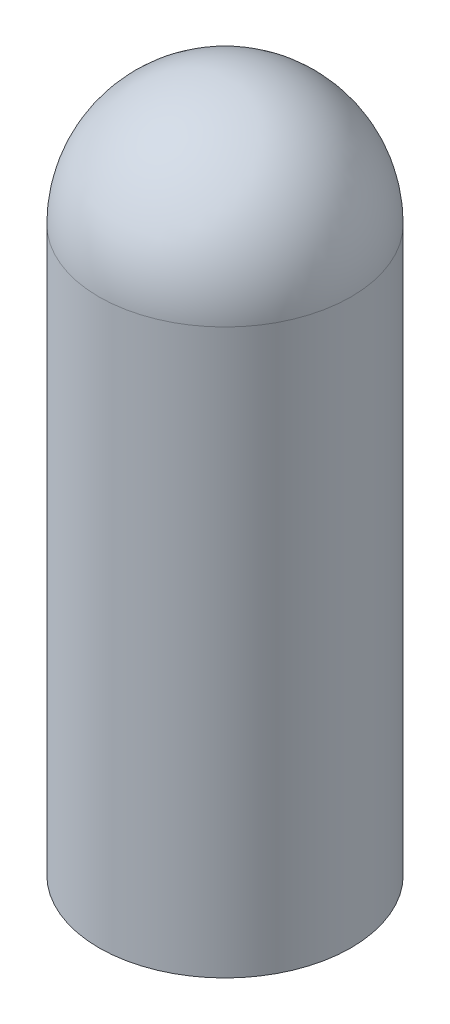
from build123d import *

# Parameters (mm, degrees)
SHELL1_T = 1.5


with BuildPart() as part:
    # Sketch1 → Revolve6 (revolve)
    with BuildSketch(Plane.XY):
        with BuildLine():
            Line((0, 42.5), (0, 52))
            ThreePointArc((0, 52), (-6.717514421, 49.217514421), (-9.5, 42.5))
            Line((-9.5, 42.5), (-9.5, 0))
            Line((-9.5, 0), (0, 0))
            Line((0, 0), (0, 42.5))
        make_face()
    revolve(axis=Axis((0, 42.5, 0), (0, 1, 0)))

    # Shell1 (no face opened: a closed hollow body)
    add(offset(amount=-SHELL1_T, mode=Mode.PRIVATE), mode=Mode.SUBTRACT)


solid = part.part
